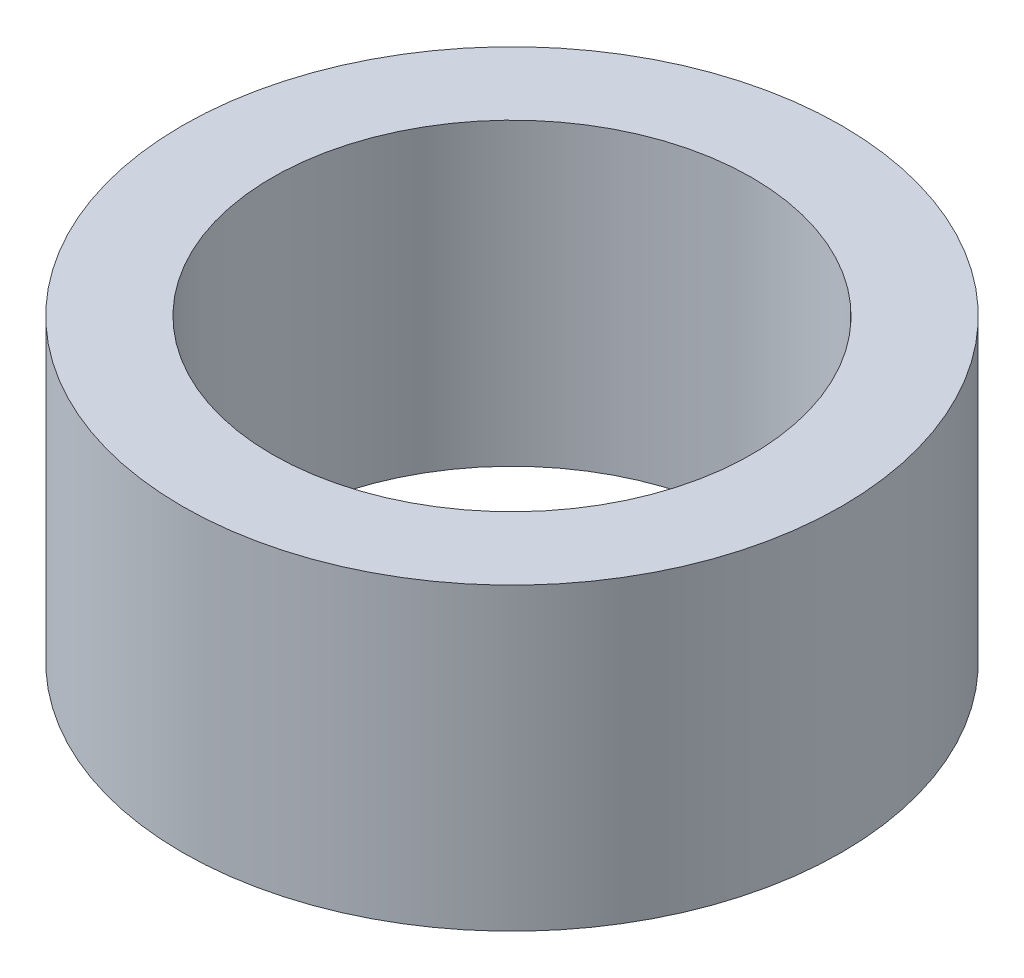
from build123d import *

# Parameters (mm, degrees)
SKETCH1_R           = 5.5
SKETCH1_R_2         = 4
BOSS_EXTRUDE1_DEPTH = 2.5


with BuildPart() as part:
    # Sketch1 → Boss-Extrude1 (new body, symmetric)
    with BuildSketch(Plane(origin=(0, 0, 0), x_dir=(1, 0, 0), z_dir=(0, 1, 0))):
        Circle(SKETCH1_R)
        Circle(SKETCH1_R_2, mode=Mode.SUBTRACT)
    extrude(amount=BOSS_EXTRUDE1_DEPTH, both=True)


solid = part.part
